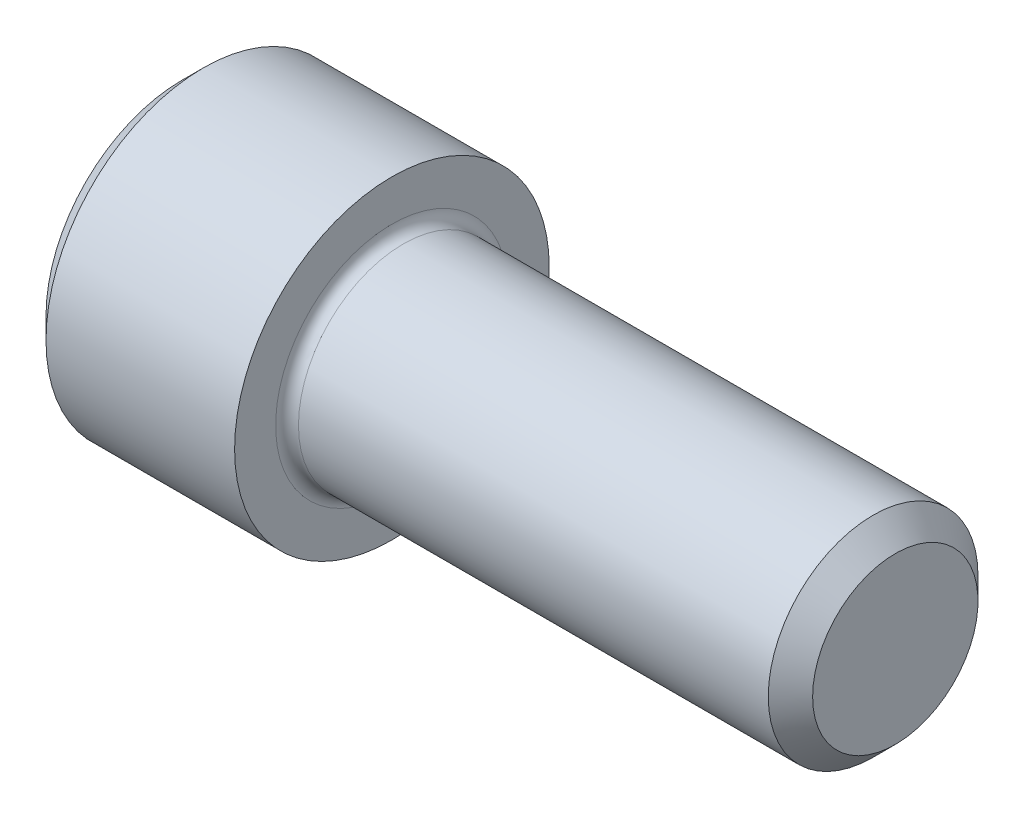
from build123d import *

# Parameters (mm, degrees)
FILLET1_R   = 0.4318
HEX_2_DEPTH = 3.8354


with BuildPart() as part:
    # BodySke → Base-Revolve (revolve)
    with BuildSketch(Plane.XY):
        Polygon((0, 0), (0, 5.15366), (0.8001, 5.95376), (7.9375, 5.95376), (7.9375, 3.96875), (26.14803, 3.96875), (26.9875, 3.12928), (26.9875, 0), align=None)
    revolve(axis=Axis((-31.75, 0, 0), (1, 0, 0)))

    # Fillet1
    fillet1_edges = [part.edges().sort_by_distance(p)[0] for p in [
        (7.9375, -3.96875, 0),
    ]]
    fillet(fillet1_edges, radius=FILLET1_R)

    # Sketch2 → Hex-PreBroach (revolve, cut)
    with BuildSketch(Plane.XY):
        Polygon((0, 3.175), (3.8354, 3.175), (5.668487105, 0), (0, 0), align=None)
    revolve(axis=Axis((0, 0, 0), (1, 0, 0)), mode=Mode.SUBTRACT)

    # Sketch3 → Hex 2 (cut)
    with BuildSketch(Plane(origin=(0, 0, 0), x_dir=(0, 0.5, 0.866025404), z_dir=(-1, 0, 0))):
        Polygon((1.833087105, 3.175), (-1.833087105, 3.175), (-3.666174209, 0), (-1.833087105, -3.175), (1.833087105, -3.175), (3.666174209, 0), align=None)
    extrude(amount=-HEX_2_DEPTH, mode=Mode.SUBTRACT)


solid = part.part
